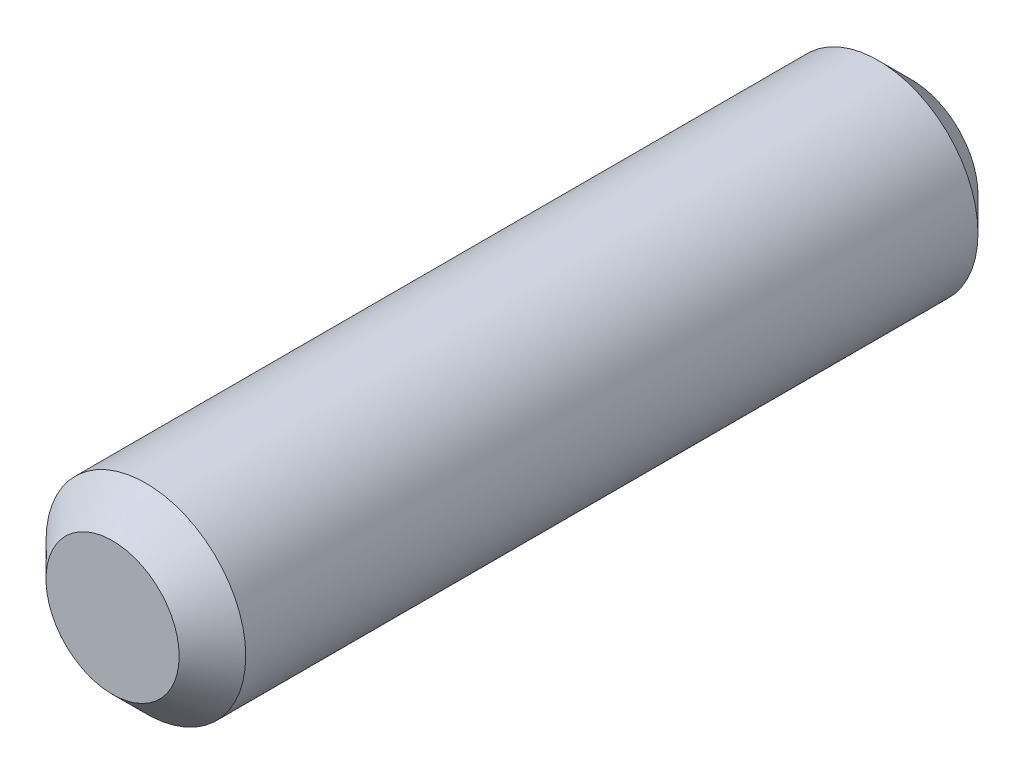
from build123d import *

# Parameters (mm, degrees)
SKETCH1_R           = 1.5
BOSS_EXTRUDE1_DEPTH = 12
CHAMFER1_SIZE       = 0.5


with BuildPart() as part:
    # Sketch1 → Boss-Extrude1 (new body)
    with BuildSketch(Plane.XY):
        Circle(SKETCH1_R)
    extrude(amount=BOSS_EXTRUDE1_DEPTH)

    # Chamfer1
    chamfer1_edges = [part.edges().sort_by_distance(p)[0] for p in [
        (-1.5, 0, 0),
        (-1.5, 0, 12),
    ]]
    chamfer(chamfer1_edges, length=CHAMFER1_SIZE)


solid = part.part
